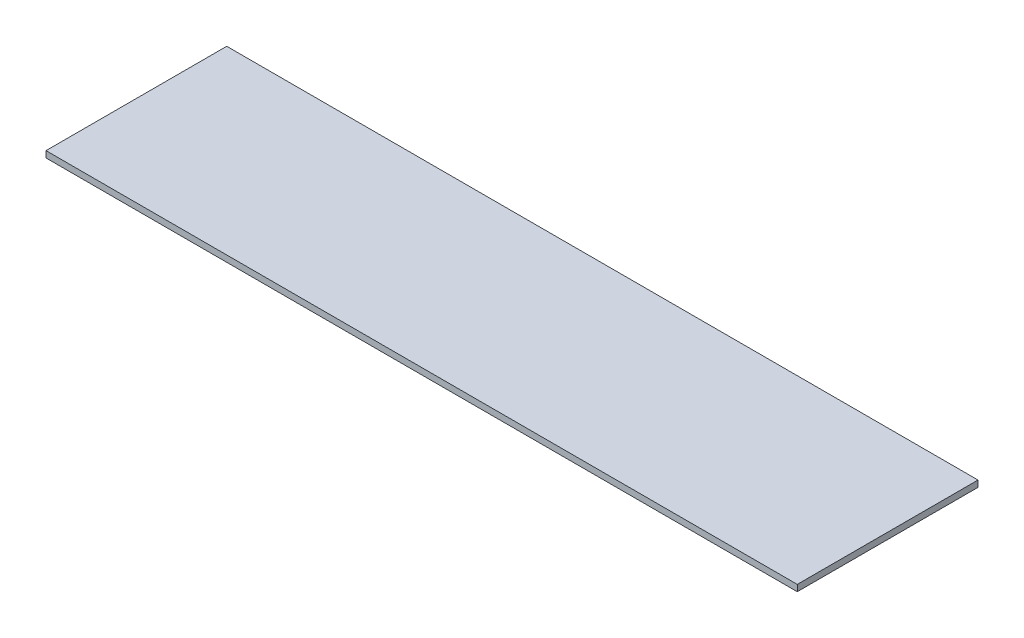
from build123d import *

# Parameters (mm, degrees)
SKETCH1_W           = 2120
SKETCH1_H           = 510
BOSS_EXTRUDE1_DEPTH = 18


with BuildPart() as part:
    # Sketch1 → Boss-Extrude1 (new body)
    with BuildSketch(Plane(origin=(0, 0, 0), x_dir=(1, 0, 0), z_dir=(0, 1, 0))):
        with Locations((1060, 255)):
            Rectangle(SKETCH1_W, SKETCH1_H)
    extrude(amount=BOSS_EXTRUDE1_DEPTH)


solid = part.part
